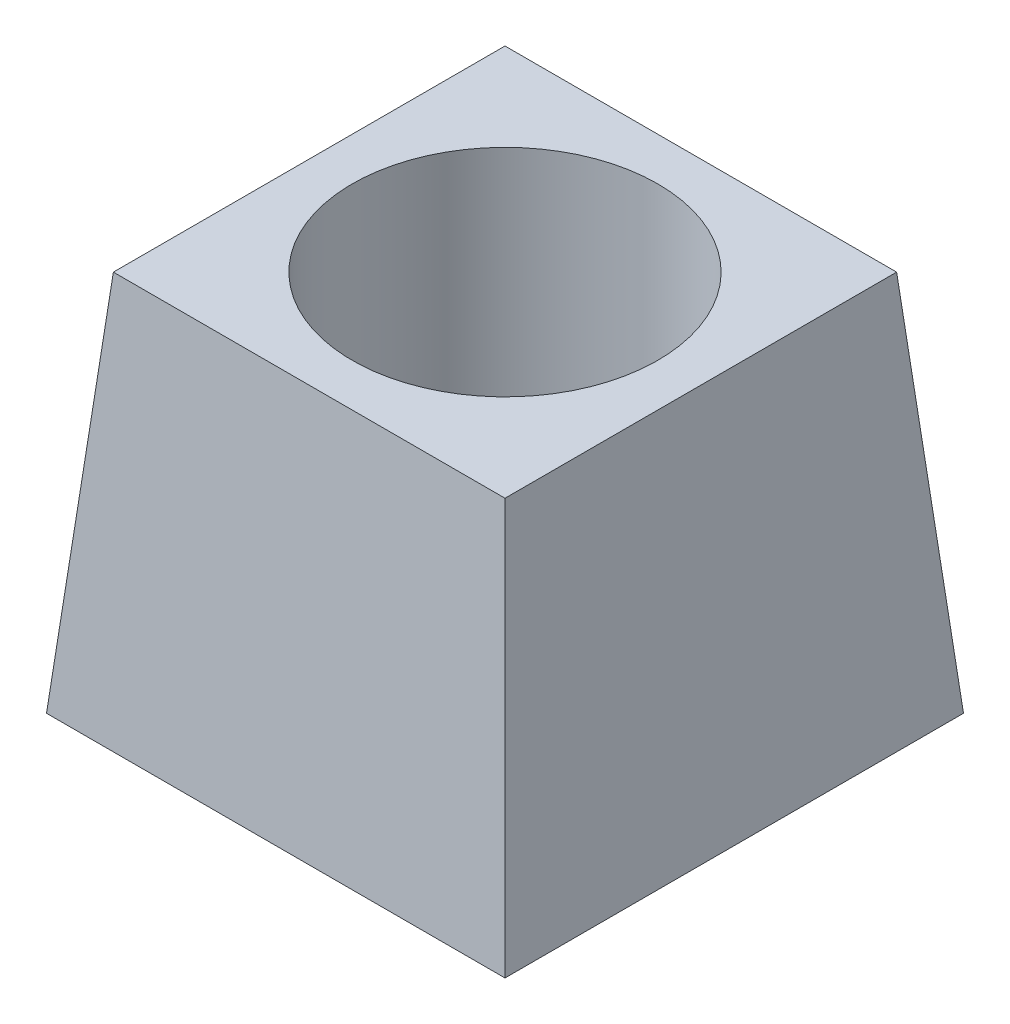
from build123d import *

# Parameters (mm, degrees)
ESQUISSE1_W             = 30
ESQUISSE1_H             = 30
EXTRUSION1_DEPTH        = 25
EXTRUSION1_TAPER        = 5
ESQUISSE2_R             = 10
ENL_V_MAT_EXTRU_1_DEPTH = 26.0000001


with BuildPart() as part:
    # Esquisse1 → Extrusion1 (new body)
    with BuildSketch(Plane(origin=(0, 0, 0), x_dir=(1, 0, 0), z_dir=(0, 1, 0))):
        with Locations((15, 15)):
            Rectangle(ESQUISSE1_W, ESQUISSE1_H)
    extrude(amount=EXTRUSION1_DEPTH, taper=EXTRUSION1_TAPER)

    # Esquisse2 → Enlèv. mat.-Extru.1 (cut, through all)
    with BuildSketch(Plane.XZ):
        with Locations((15, -15)):
            Circle(ESQUISSE2_R)
    extrude(amount=-ENL_V_MAT_EXTRU_1_DEPTH, mode=Mode.SUBTRACT)


solid = part.part
